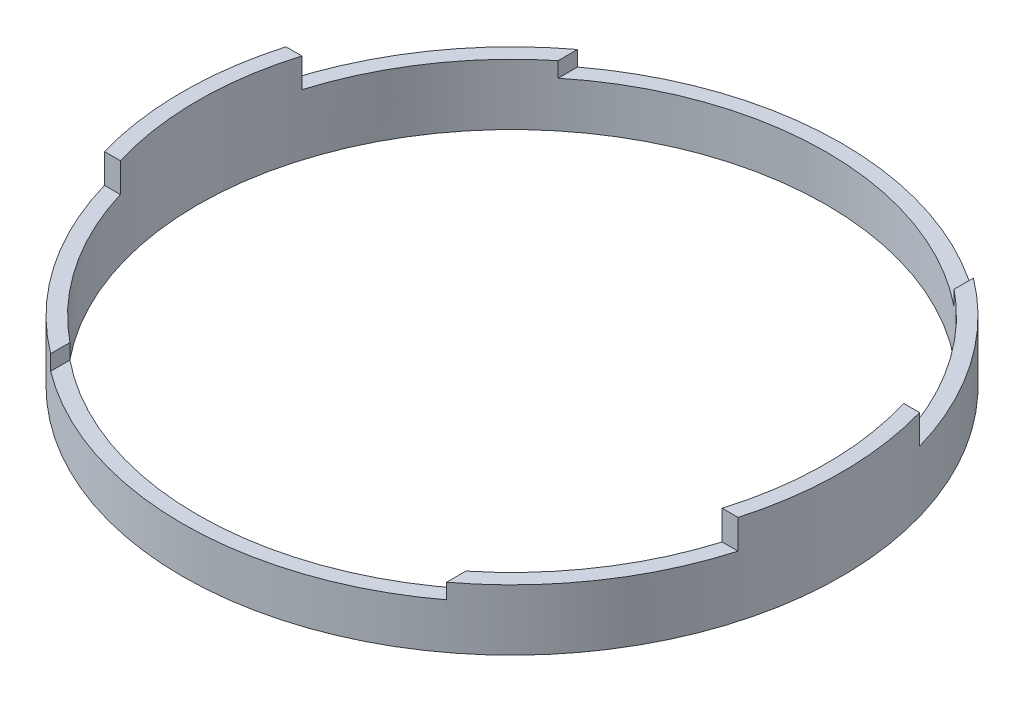
from build123d import *

# Parameters (mm, degrees)
SKETCH1_R           = 68.707
SKETCH1_R_2         = 65.532
BOSS_EXTRUDE1_DEPTH = 6.35
CUT_EXTRUDE1_DEPTH  = 3.175
BOSS_EXTRUDE2_DEPTH = 6.096


with BuildPart() as part:
    # Sketch1 → Boss-Extrude1 (new body, symmetric)
    with BuildSketch(Plane(origin=(0, 0, 0), x_dir=(1, 0, 0), z_dir=(0, 1, 0))):
        Circle(SKETCH1_R)
        Circle(SKETCH1_R_2, mode=Mode.SUBTRACT)
    extrude(amount=BOSS_EXTRUDE1_DEPTH, both=True)

    # Sketch2 → Cut-Extrude1 (cut)
    with BuildSketch(Plane(origin=(0, 6.35, 0), x_dir=(1, 0, 0), z_dir=(0, 1, 0))):
        with BuildLine():
            Line((-41.275, -50.900073), (-41.275, -54.927463))
            ThreePointArc((-41.275, -54.927463), (0, -68.707), (41.275, -54.927463))
            Line((41.275, -54.927463), (41.275, -50.900073))
            ThreePointArc((41.275, -50.900073), (0, -65.532), (-41.275, -50.900073))
        make_face()
    cut_extrude1 = extrude(amount=-CUT_EXTRUDE1_DEPTH, mode=Mode.SUBTRACT)

    # Mirror1: Cut-Extrude1 across plane
    add(cut_extrude1.mirror(Plane.XY), mode=Mode.SUBTRACT)

    # Sketch4 → Boss-Extrude2 (add)
    with BuildSketch(Plane(origin=(0, 6.35, 0), x_dir=(1, 0, 0), z_dir=(0, 1, 0))):
        with BuildLine():
            Line((-62.740442, 18.923), (-66.049769, 18.923))
            ThreePointArc((-66.049769, 18.923), (-68.707, 0), (-66.049769, -18.923))
            Line((-66.049769, -18.923), (-62.740442, -18.923))
            ThreePointArc((-62.740442, -18.923), (-65.532, 0), (-62.740442, 18.923))
        make_face()
    boss_extrude2 = extrude(amount=BOSS_EXTRUDE2_DEPTH)

    # Mirror3: Boss-Extrude2 across plane
    add(boss_extrude2.mirror(Plane(origin=(0, 0, 0), x_dir=(0, 0, 1), z_dir=(1, 0, 0))))


solid = part.part
